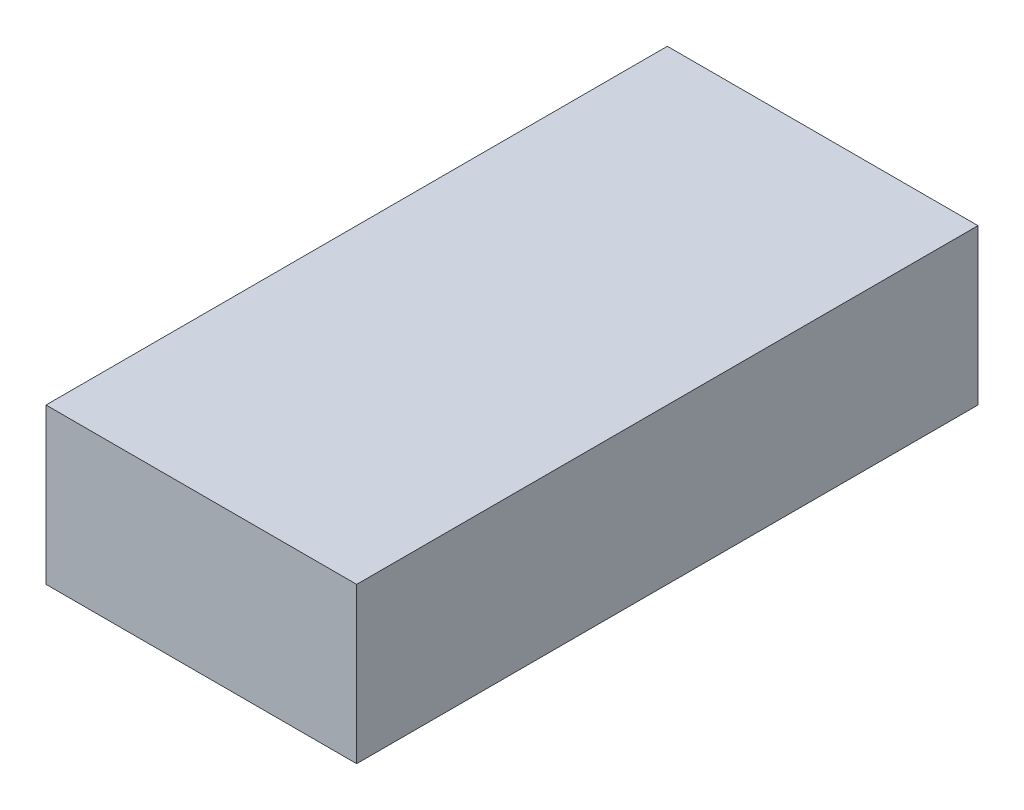
from build123d import *

# Parameters (mm, degrees)
SKETCH1_W           = 10
SKETCH1_H           = 5
BOSS_EXTRUDE1_DEPTH = 20


with BuildPart() as part:
    # Sketch1 → Boss-Extrude1 (new body)
    with BuildSketch(Plane.XY):
        Rectangle(SKETCH1_W, SKETCH1_H)
    extrude(amount=BOSS_EXTRUDE1_DEPTH)


solid = part.part
